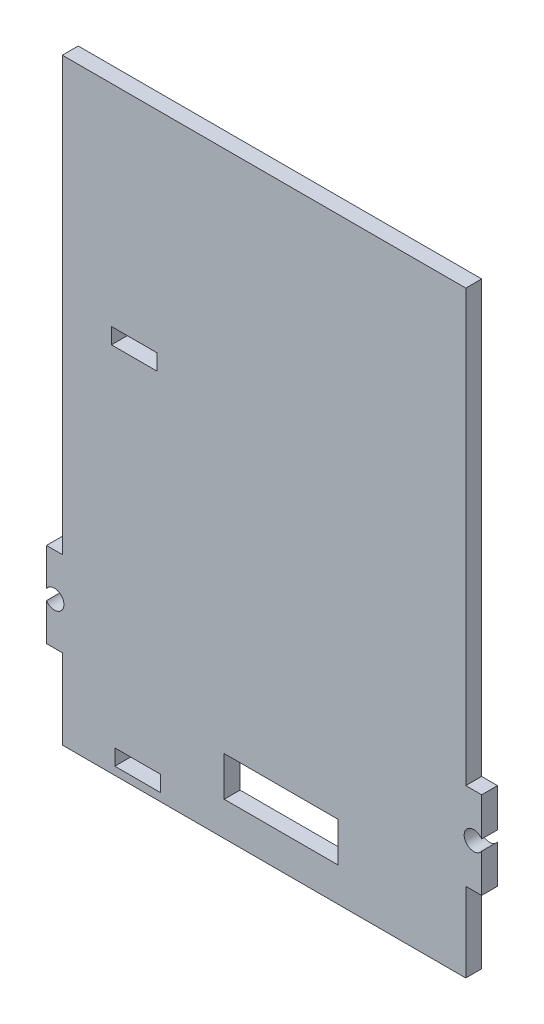
from build123d import *

# Parameters (mm, degrees)
SKETCH1_W           = 87
SKETCH1_H           = 44.45
SKETCH1_W_2         = 9.142679105
SKETCH1_H_2         = 3.175
BOSS_EXTRUDE1_DEPTH = 3.175
SKETCH2_W           = 3.175
SKETCH2_H           = 11.14
CUT_EXTRUDE1_DEPTH  = 4.175
SKETCH3_W           = 3.175
SKETCH3_H           = 15.88
CUT_EXTRUDE2_DEPTH  = 4.175
SKETCH6_R           = 1.905
CUT_EXTRUDE3_DEPTH  = 4.175
SKETCH8_W           = 3.175
SKETCH8_H           = 11.469011162
SKETCH8_H_2         = 15.983017012
CUT_EXTRUDE4_DEPTH  = 4.175
SKETCH10_R          = 1.905
CUT_EXTRUDE5_DEPTH  = 4.175
SKETCH12_W          = 80.65
SKETCH12_H          = 3.175
BOSS_EXTRUDE2_DEPTH = 75
SKETCH18_W          = 9.14
SKETCH18_H          = 3.18
CUT_EXTRUDE6_DEPTH  = 3.18
SKETCH19_W          = 22.786874906
SKETCH19_H          = 7.908464624
CUT_EXTRUDE7_DEPTH  = 3.18


with BuildPart() as part:
    # Sketch1 → Boss-Extrude1 (new body)
    with BuildSketch(Plane.XY):
        with Locations((43.5, -22.225)):
            Rectangle(SKETCH1_W, SKETCH1_H)
        with Locations((18.232073224, -41.2725)):
            Rectangle(SKETCH1_W_2, SKETCH1_H_2, mode=Mode.SUBTRACT)
    extrude(amount=BOSS_EXTRUDE1_DEPTH)

    # Sketch2 → Cut-Extrude1 (cut, through all)
    with BuildSketch(Plane(origin=(0, 0, 0), x_dir=(-1, 0, 0), z_dir=(0, 0, -1))):
        with Locations((-85.4125, -5.57)):
            Rectangle(SKETCH2_W, SKETCH2_H)
    extrude(amount=-CUT_EXTRUDE1_DEPTH, mode=Mode.SUBTRACT)

    # Sketch3 → Cut-Extrude2 (cut, through all)
    with BuildSketch(Plane(origin=(0, 0, 0), x_dir=(-1, 0, 0), z_dir=(0, 0, -1))):
        with Locations((-85.4125, -36.51)):
            Rectangle(SKETCH3_W, SKETCH3_H)
    extrude(amount=-CUT_EXTRUDE2_DEPTH, mode=Mode.SUBTRACT)

    # Sketch6 → Cut-Extrude3 (cut, through all)
    with BuildSketch(Plane(origin=(0, 0, 0), x_dir=(-1, 0, 0), z_dir=(0, 0, -1))):
        with Locations((-85.4125, -19.855)):
            Circle(SKETCH6_R)
    extrude(amount=-CUT_EXTRUDE3_DEPTH, mode=Mode.SUBTRACT)

    # Sketch8 → Cut-Extrude4 (cut, through all)
    with BuildSketch(Plane(origin=(0, 0, 0), x_dir=(-1, 0, 0), z_dir=(0, 0, -1))):
        with Locations((-1.5875, -5.734505581)):
            Rectangle(SKETCH8_W, SKETCH8_H)
        with Locations((-1.5875, -36.458491494)):
            Rectangle(SKETCH8_W, SKETCH8_H_2)
    extrude(amount=-CUT_EXTRUDE4_DEPTH, mode=Mode.SUBTRACT)

    # Sketch10 → Cut-Extrude5 (cut, through all)
    with BuildSketch(Plane(origin=(0, 0, 0), x_dir=(-1, 0, 0), z_dir=(0, 0, -1))):
        with Locations((-1.5875, -19.967997075)):
            Circle(SKETCH10_R)
    extrude(amount=-CUT_EXTRUDE5_DEPTH, mode=Mode.SUBTRACT)

    # Sketch12 → Boss-Extrude2 (add)
    with BuildSketch(Plane(origin=(0, 0, 0), x_dir=(1, 0, 0), z_dir=(0, 1, 0))):
        with Locations((43.5, -1.5875)):
            Rectangle(SKETCH12_W, SKETCH12_H)
    extrude(amount=BOSS_EXTRUDE2_DEPTH)

    # Sketch18 → Cut-Extrude6 (cut)
    with BuildSketch(Plane.XY.offset(3.175)):
        with Locations((17.561709366, 31.346582601)):
            Rectangle(SKETCH18_W, SKETCH18_H)
    extrude(amount=-CUT_EXTRUDE6_DEPTH, mode=Mode.SUBTRACT)

    # Sketch19 → Cut-Extrude7 (cut)
    with BuildSketch(Plane.XY.offset(3.175)):
        with Locations((46.923268397, -33.695818912)):
            Rectangle(SKETCH19_W, SKETCH19_H)
    extrude(amount=-CUT_EXTRUDE7_DEPTH, mode=Mode.SUBTRACT)


solid = part.part
